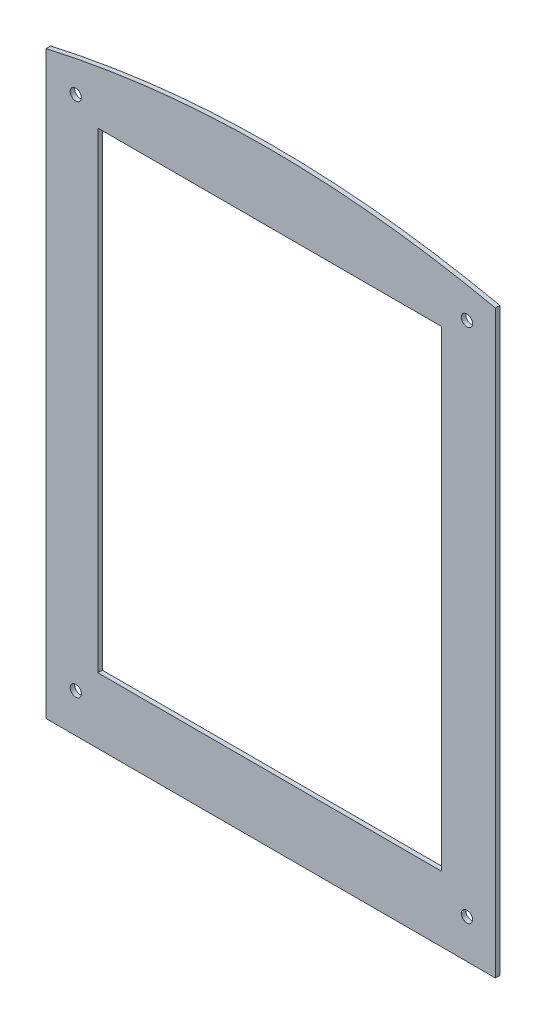
from build123d import *

# Parameters (mm, degrees)
SKETCH1_R           = 2.5
SKETCH1_W           = 153
SKETCH1_H           = 210
BOSS_EXTRUDE1_DEPTH = 2


with BuildPart() as part:
    # Sketch1 → Boss-Extrude1 (new body)
    with BuildSketch(Plane.XY):
        with BuildLine():
            Line((79.989677419, 0), (-120.010322581, 0))
            Line((-120.010322581, 0), (-120.010322581, 258.3))
            add(Edge.make_bspline(
                [(-120.010322581, 258.3), (-22.49451042, 280.450990468), (79.989677419, 258.3)],
                knots=[0, 0, 0, 1, 1, 1], degree=2))
            Line((79.989677419, 258.3), (79.989677419, 0))
        make_face()
        with Locations((-106.803669914, 247.177426871)):
            Circle(SKETCH1_R, mode=Mode.SUBTRACT)
        with Locations((67.322454172, 247.177426871)):
            Circle(SKETCH1_R, mode=Mode.SUBTRACT)
        with Locations((67.322454172, 17.342199543)):
            Circle(SKETCH1_R, mode=Mode.SUBTRACT)
        with Locations((-106.803669914, 17.342199543)):
            Circle(SKETCH1_R, mode=Mode.SUBTRACT)
        with Locations((-20.502905322, 134.178843816)):
            Rectangle(SKETCH1_W, SKETCH1_H, mode=Mode.SUBTRACT)
    extrude(amount=BOSS_EXTRUDE1_DEPTH)


solid = part.part
